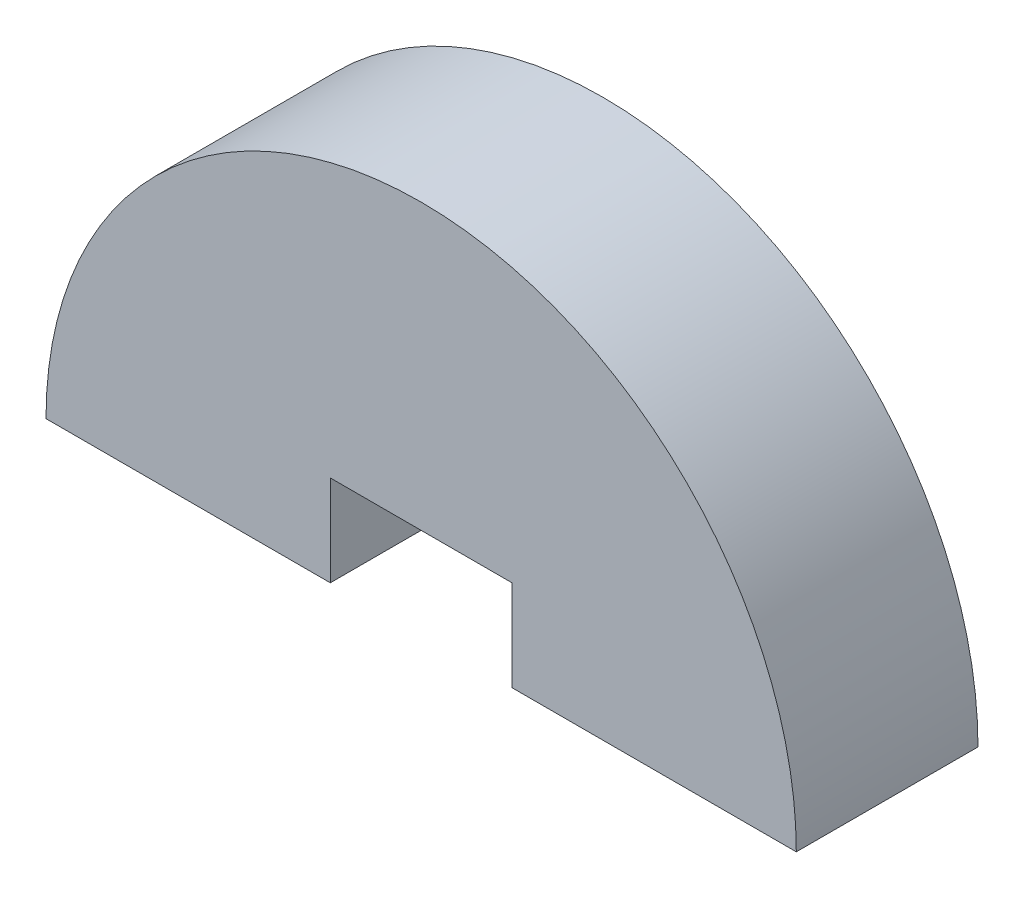
from build123d import *

# Parameters (mm, degrees)
BOSS_EXTRUDE1_DEPTH = 6


with BuildPart() as part:
    # Model → Boss-Extrude1 (new body)
    with BuildSketch(Plane.XY):
        with BuildLine():
            Line((3761.808823463, 1712.089930422), (3771.1973296, 1712.089930422))
            Line((3771.1973296, 1712.089930422), (3771.1973296, 1715.089930422))
            Line((3771.1973296, 1715.089930422), (3777.1973296, 1715.089930422))
            Line((3777.1973296, 1715.089930422), (3777.1973296, 1712.089930422))
            Line((3777.1973296, 1712.089930422), (3786.585835737, 1712.089930422))
            ThreePointArc((3786.585835737, 1712.089930422), (3774.1973296, 1724.47843656), (3761.808823463, 1712.089930422))
        make_face()
    extrude(amount=BOSS_EXTRUDE1_DEPTH)


solid = part.part
